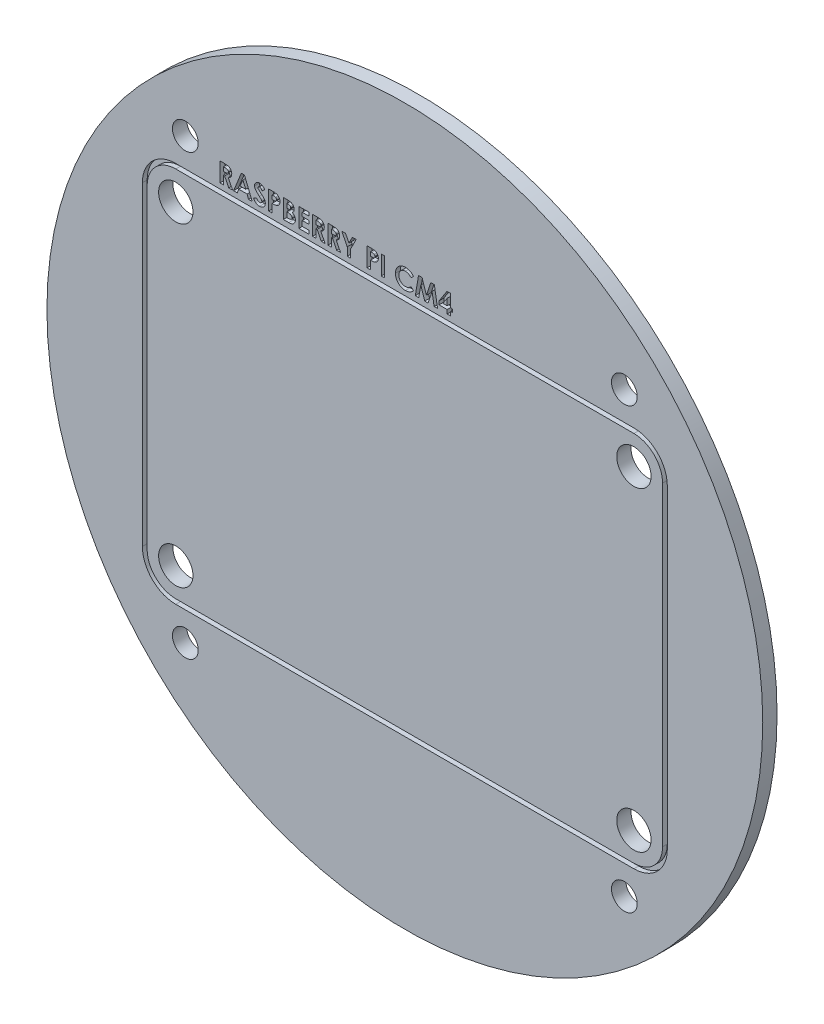
from build123d import *

# Parameters (mm, degrees)
ESQUISSE1_R             = 37.5
BOSS_EXTRU_1_DEPTH      = 1.5
D_GAGEMENT_M2_51_D      = 2.7
D_GAGEMENT_M31_D        = 3.6
ENL_V_MAT_EXTRU_1_DEPTH = 0.5
ESQUISSE7_W             = 0.358974359
ESQUISSE7_H             = 2
ENL_V_MAT_EXTRU_2_DEPTH = 0.5


with BuildPart() as part:
    # Esquisse1 → Boss.-Extru.1 (new body)
    with BuildSketch(Plane.XY):
        Circle(ESQUISSE1_R)
    extrude(amount=BOSS_EXTRU_1_DEPTH)

    # Dégagement M2.51 (through all)
    with Locations(Plane.XY.offset(1.5)):
        with Locations((-23, 23), (23, 23), (23, -23), (-23, -23)):
            Hole(D_GAGEMENT_M2_51_D / 2)

    # Dégagement M31 (through all)
    with Locations(Plane.XY.offset(1.5)):
        with Locations((-24, 16.5), (24, 16.5), (24, -16.5), (-24, -16.5)):
            Hole(D_GAGEMENT_M31_D / 2)

    # Esquisse6 → Enlèv. mat.-Extru.1 (cut)
    with BuildSketch(Plane.XY.offset(1.5)):
        with BuildLine():
            Line((-27.5, 16.5), (-27.5, -16.5))
            ThreePointArc((-27.5, -16.5), (-26.474873734, -18.974873734), (-24, -20))
            Line((-24, -20), (24, -20))
            ThreePointArc((24, -20), (26.474873734, -18.974873734), (27.5, -16.5))
            Line((27.5, -16.5), (27.5, 16.5))
            ThreePointArc((27.5, 16.5), (26.474873734, 18.974873734), (24, 20))
            Line((24, 20), (-24, 20))
            ThreePointArc((-24, 20), (-26.474873734, 18.974873734), (-27.5, 16.5))
        make_face()
        with BuildLine():
            Line((-24, 19.5), (24, 19.5))
            ThreePointArc((24, 19.5), (26.121320344, 18.621320344), (27, 16.5))
            Line((27, 16.5), (27, -16.5))
            ThreePointArc((27, -16.5), (26.121320344, -18.621320344), (24, -19.5))
            Line((24, -19.5), (-24, -19.5))
            ThreePointArc((-24, -19.5), (-26.121320344, -18.621320344), (-27, -16.5))
            Line((-27, -16.5), (-27, 16.5))
            ThreePointArc((-27, 16.5), (-26.121320344, 18.621320344), (-24, 19.5))
        make_face(mode=Mode.SUBTRACT)
    extrude(amount=-ENL_V_MAT_EXTRU_1_DEPTH, mode=Mode.SUBTRACT)

    # Esquisse7 → Enlèv. mat.-Extru.2 (cut)
    with BuildSketch(Plane.XY.offset(1.5)):
        with BuildLine():
            Line((-19.36550309, 22.554763031), (-18.947233859, 22.554763031))
            add(Edge.make_bspline(
                [(-18.947233859, 22.554763031), (-18.91958639, 22.554664898), (-18.86641252, 22.554476162), (-18.789738703, 22.551498396), (-18.719303258, 22.547354591), (-18.655001898, 22.541031034), (-18.596862133, 22.532646763), (-18.544825694, 22.522763094), (-18.498894101, 22.511498534), (-18.458679984, 22.497462003), (-18.422388732, 22.48162901), (-18.38856024, 22.46343661), (-18.356448201, 22.443087382), (-18.326267249, 22.420045883), (-18.297755104, 22.394726623), (-18.270857977, 22.367104116), (-18.245955949, 22.336944135), (-18.223203215, 22.304437252), (-18.202465929, 22.270240757), (-18.184138518, 22.234307697), (-18.169234636, 22.196613084), (-18.156065459, 22.157701686), (-18.146580128, 22.117017256), (-18.139983218, 22.074955866), (-18.135153219, 22.031369454), (-18.134875518, 22.001758781), (-18.134733859, 21.986654057)],
                knots=[0, 0, 0, 0, 8.2937e-05, 0.00015951, 0.000230161, 0.000294583, 0.000353282, 0.00040632, 0.000453447, 0.000495006, 0.000533936, 0.000572115, 0.000610125, 0.000647867, 0.000685896, 0.000724428, 0.000763414, 0.000803096, 0.00084336, 0.000883316, 0.000923937, 0.000964859, 0.00100645, 0.001049066, 0.001092559, 0.001137847, 0.001137847, 0.001137847, 0.001137847], degree=3))
            add(Edge.make_bspline(
                [(-18.134733859, 21.986654057), (-18.135101837, 21.970888195), (-18.135823376, 21.939974213), (-18.139709975, 21.894564094), (-18.146813457, 21.85111887), (-18.157572715, 21.80976574), (-18.169939084, 21.769990019), (-18.186383182, 21.732525592), (-18.204941973, 21.696827595), (-18.226983706, 21.663400987), (-18.251173432, 21.631503299), (-18.279305573, 21.602356649), (-18.309557601, 21.574394513), (-18.343630091, 21.549368347), (-18.380021096, 21.525585971), (-18.419453668, 21.504032804), (-18.461670455, 21.484167051), (-18.491350948, 21.473088534), (-18.506528731, 21.467423287)],
                knots=[0, 0, 0, 0, 4.7303e-05, 9.2752e-05, 0.000136618, 0.000179179, 0.000220863, 0.000261423, 0.000301746, 0.000341418, 0.000381406, 0.00042165, 0.000462775, 0.000504843, 0.000548293, 0.000593122, 0.000639545, 0.000688128, 0.000688128, 0.000688128, 0.000688128], degree=3))
            Line((-18.506528731, 21.467423287), (-18.044990269, 20.554763031))
            Line((-18.044990269, 20.554763031), (-18.444028731, 20.554763031))
            Line((-18.444028731, 20.554763031), (-18.884733859, 21.426557903))
            Line((-18.884733859, 21.426557903), (-19.006528731, 21.426557903))
            Line((-19.006528731, 21.426557903), (-19.006528731, 20.554763031))
            Line((-19.006528731, 20.554763031), (-19.36550309, 20.554763031))
            Line((-19.36550309, 20.554763031), (-19.36550309, 22.554763031))
        make_face()
        with BuildLine():
            Line((-19.006528731, 21.785532262), (-18.866705013, 21.785532262))
            add(Edge.make_bspline(
                [(-18.866705013, 21.785532262), (-18.849610401, 21.785724793), (-18.816877893, 21.786093448), (-18.769804246, 21.787803425), (-18.727050149, 21.791923625), (-18.688432, 21.797129344), (-18.653755477, 21.803140097), (-18.623329881, 21.811753872), (-18.596686402, 21.82098375), (-18.574140764, 21.832454094), (-18.554878289, 21.845498363), (-18.538246375, 21.860316977), (-18.524489397, 21.877467636), (-18.513166703, 21.896484258), (-18.504358878, 21.917535042), (-18.49792984, 21.940388897), (-18.494336959, 21.965306158), (-18.493923586, 21.982502461), (-18.493708218, 21.991461749)],
                knots=[0, 0, 0, 0, 5.1288e-05, 9.8206e-05, 0.000141261, 0.000180074, 0.00021512, 0.00024671, 0.000274846, 0.000299573, 0.000322353, 0.000344479, 0.000366129, 0.000388047, 0.000410668, 0.000434387, 0.000459091, 0.000485961, 0.000485961, 0.000485961, 0.000485961], degree=3))
            add(Edge.make_bspline(
                [(-18.493708218, 21.991461749), (-18.49411539, 22.002061241), (-18.494915205, 22.022881979), (-18.502851855, 22.052856541), (-18.515485288, 22.080600049), (-18.532802263, 22.105987151), (-18.554610743, 22.128243237), (-18.579637694, 22.147862154), (-18.608423258, 22.163375326), (-18.635076524, 22.173607649), (-18.659324766, 22.179729753), (-18.68120804, 22.184291891), (-18.706549002, 22.187525209), (-18.735366785, 22.190954719), (-18.76758793, 22.193178582), (-18.803388062, 22.194801559), (-18.842664364, 22.195465598), (-18.870043676, 22.19567788), (-18.884333218, 22.195788672)],
                knots=[0, 0, 0, 0, 3.1742e-05, 6.2351e-05, 9.2292e-05, 0.000122851, 0.000154019, 0.000185433, 0.000217887, 0.000251743, 0.000270789, 0.000292868, 0.000318762, 0.000347387, 0.000379928, 0.000415621, 0.000454892, 0.000497762, 0.000497762, 0.000497762, 0.000497762], degree=3))
            Line((-18.884333218, 22.195788672), (-19.006528731, 22.195788672))
            Line((-19.006528731, 22.195788672), (-19.006528731, 21.785532262))
        make_face(mode=Mode.SUBTRACT)
        Polygon((-17.134333218, 22.554763031), (-16.801400526, 22.554763031), (-15.993708218, 20.554763031), (-16.377121679, 20.554763031), (-16.532570397, 20.965019441), (-17.403964628, 20.965019441), (-17.559413346, 20.554763031), (-17.942426167, 20.554763031), align=None)
        Polygon((-16.968067192, 22.018304698), (-17.267746679, 21.3239938), (-16.668387705, 21.3239938), align=None, mode=Mode.SUBTRACT)
        with BuildLine():
            Line((-14.673195397, 22.287535467), (-14.941624885, 22.041942518))
            add(Edge.make_bspline(
                [(-14.941624885, 22.041942518), (-14.953123253, 22.058162162), (-14.975198516, 22.089301616), (-15.010980216, 22.130998079), (-15.046600343, 22.166568265), (-15.082388896, 22.195863578), (-15.118663091, 22.218706028), (-15.155359962, 22.234878734), (-15.192271463, 22.245159877), (-15.217070294, 22.246440127), (-15.229285141, 22.247070723)],
                knots=[0, 0, 0, 0, 5.9619e-05, 0.00011446, 0.000164604, 0.000210468, 0.000252936, 0.000292761, 0.000330466, 0.000367065, 0.000367065, 0.000367065, 0.000367065], degree=3))
            add(Edge.make_bspline(
                [(-15.229285141, 22.247070723), (-15.2406788, 22.246671149), (-15.262676961, 22.245899675), (-15.294036972, 22.238231281), (-15.321878836, 22.22499676), (-15.346175382, 22.20769151), (-15.36542183, 22.186842695), (-15.380788627, 22.16497765), (-15.389441425, 22.140843584), (-15.390580303, 22.124267335), (-15.391144115, 22.116061108)],
                knots=[0, 0, 0, 0, 3.4139e-05, 6.5914e-05, 9.6023e-05, 0.000126157, 0.000154782, 0.000180784, 0.000205874, 0.000230474, 0.000230474, 0.000230474, 0.000230474], degree=3))
            add(Edge.make_bspline(
                [(-15.391144115, 22.116061108), (-15.390790803, 22.107736544), (-15.39007928, 22.090972028), (-15.383206941, 22.066401542), (-15.372848363, 22.042393318), (-15.362950319, 22.027778369), (-15.35789091, 22.020307903)],
                knots=[0, 0, 0, 0, 2.492e-05, 5.0186e-05, 7.6017e-05, 0.000103027, 0.000103027, 0.000103027, 0.000103027], degree=3))
            add(Edge.make_bspline(
                [(-15.35789091, 22.020307903), (-15.35329136, 22.014501188), (-15.342703803, 22.001134896), (-15.322515501, 21.979964774), (-15.297163233, 21.954029521), (-15.265671391, 21.924220974), (-15.229347288, 21.889467103), (-15.186507254, 21.851134095), (-15.138384414, 21.80803482), (-15.104179813, 21.778022046), (-15.086256295, 21.762295082)],
                knots=[0, 0, 0, 0, 2.2213e-05, 5.1131e-05, 8.7678e-05, 0.00013103, 0.000181194, 0.00023849, 0.000303469, 0.000375003, 0.000375003, 0.000375003, 0.000375003], degree=3))
            add(Edge.make_bspline(
                [(-15.086256295, 21.762295082), (-15.069432495, 21.747734932), (-15.037504417, 21.720102791), (-14.992077103, 21.680883404), (-14.952154059, 21.645598678), (-14.917153699, 21.61477816), (-14.887606594, 21.588098474), (-14.863388527, 21.565432091), (-14.844203715, 21.547220283), (-14.833298273, 21.53622034), (-14.828644115, 21.531525852)],
                knots=[0, 0, 0, 0, 6.6749e-05, 0.000126675, 0.000180043, 0.00022659, 0.000266584, 0.000299465, 0.000326101, 0.000345932, 0.000345932, 0.000345932, 0.000345932], degree=3))
            add(Edge.make_bspline(
                [(-14.828644115, 21.531525852), (-14.81098721, 21.512417298), (-14.777044437, 21.475683948), (-14.732930798, 21.418758809), (-14.696623845, 21.363188265), (-14.668536099, 21.307926667), (-14.647323103, 21.252176701), (-14.63236766, 21.194571101), (-14.623410745, 21.134507925), (-14.622416319, 21.093522139), (-14.621913346, 21.072791877)],
                knots=[0, 0, 0, 0, 7.8022e-05, 0.000149986, 0.000215775, 0.000276874, 0.000335583, 0.000394373, 0.000455112, 0.000517275, 0.000517275, 0.000517275, 0.000517275], degree=3))
            add(Edge.make_bspline(
                [(-14.621913346, 21.072791877), (-14.622271349, 21.052592779), (-14.622973764, 21.012961397), (-14.631577003, 20.954966773), (-14.643844716, 20.899463401), (-14.662812753, 20.847055235), (-14.685930884, 20.796882013), (-14.714912801, 20.749725273), (-14.748948088, 20.705107769), (-14.787957752, 20.663827095), (-14.831107073, 20.626367744), (-14.877388821, 20.593020545), (-14.927255561, 20.565488185), (-14.980281241, 20.54281725), (-15.036437477, 20.525355793), (-15.095657369, 20.512450149), (-15.1580315, 20.504704385), (-15.200683829, 20.503894657), (-15.222474244, 20.50348098)],
                knots=[0, 0, 0, 0, 6.0545e-05, 0.000118791, 0.000175546, 0.000230794, 0.000285639, 0.000341021, 0.000396471, 0.000453722, 0.000511085, 0.000567672, 0.000624525, 0.000681604, 0.000740398, 0.000800672, 0.000863236, 0.000928585, 0.000928585, 0.000928585, 0.000928585], degree=3))
            add(Edge.make_bspline(
                [(-15.222474244, 20.50348098), (-15.239579534, 20.503784439), (-15.273457818, 20.504385462), (-15.323389287, 20.509292318), (-15.371603766, 20.51721146), (-15.418046943, 20.528561957), (-15.462928055, 20.542944575), (-15.506248944, 20.560512393), (-15.547710552, 20.581537704), (-15.587626597, 20.605588145), (-15.625803038, 20.633513875), (-15.662722601, 20.664743962), (-15.698018566, 20.699758738), (-15.731860451, 20.738475394), (-15.764031728, 20.781003568), (-15.795585478, 20.826750975), (-15.825119357, 20.876566626), (-15.843363747, 20.911512707), (-15.852682577, 20.92936239)],
                knots=[0, 0, 0, 0, 5.1307e-05, 0.000101617, 0.000150358, 0.000197777, 0.00024491, 0.000291632, 0.000337859, 0.000384238, 0.000431279, 0.000479603, 0.00052918, 0.000580287, 0.000633734, 0.000689075, 0.000746929, 0.000807331, 0.000807331, 0.000807331, 0.000807331], degree=3))
            Line((-15.852682577, 20.92936239), (-15.536977449, 21.118865595))
            add(Edge.make_bspline(
                [(-15.536977449, 21.118865595), (-15.525320985, 21.098603873), (-15.502974549, 21.05976042), (-15.465106424, 21.007569318), (-15.426312463, 20.962876278), (-15.385695784, 20.926471253), (-15.343750272, 20.89786746), (-15.300273319, 20.877425206), (-15.25523438, 20.864771473), (-15.2245559, 20.86322616), (-15.20925309, 20.862455339)],
                knots=[0, 0, 0, 0, 7.0084e-05, 0.000134356, 0.000193114, 0.000247313, 0.000297539, 0.000344857, 0.000390924, 0.000436772, 0.000436772, 0.000436772, 0.000436772], degree=3))
            add(Edge.make_bspline(
                [(-15.20925309, 20.862455339), (-15.193687941, 20.863084833), (-15.163489284, 20.864306145), (-15.120384567, 20.875587029), (-15.08086453, 20.893298844), (-15.046703702, 20.918571163), (-15.017778466, 20.947739259), (-14.996429982, 20.9801901), (-14.983018721, 21.015301127), (-14.981600825, 21.039691556), (-14.980887705, 21.051958544)],
                knots=[0, 0, 0, 0, 4.6614e-05, 9.0438e-05, 0.000132747, 0.000175782, 0.000217147, 0.000255374, 0.000291623, 0.0003283, 0.0003283, 0.0003283, 0.0003283], degree=3))
            add(Edge.make_bspline(
                [(-14.980887705, 21.051958544), (-14.981546242, 21.06337098), (-14.982883998, 21.086554252), (-14.992737493, 21.121024048), (-15.00814151, 21.155478169), (-15.02636555, 21.183738371), (-15.044910792, 21.207399872), (-15.062644226, 21.227901492), (-15.084238858, 21.250552194), (-15.109639932, 21.275380469), (-15.138511836, 21.302604887), (-15.170878889, 21.332222783), (-15.207111728, 21.363973258), (-15.232721171, 21.385601368), (-15.246112064, 21.396910467)],
                knots=[0, 0, 0, 0, 3.4205e-05, 6.9484e-05, 0.000106787, 0.000147132, 0.000169972, 0.000196959, 0.000228416, 0.000263829, 0.000303507, 0.000347462, 0.000395441, 0.000448022, 0.000448022, 0.000448022, 0.000448022], degree=3))
            add(Edge.make_bspline(
                [(-15.246112064, 21.396910467), (-15.271568685, 21.418449209), (-15.320427645, 21.459788575), (-15.389471555, 21.520845517), (-15.4516863, 21.577908824), (-15.506534527, 21.631683922), (-15.554715086, 21.681177712), (-15.595901679, 21.7267922), (-15.629641852, 21.768879239), (-15.665146108, 21.81872852), (-15.69888225, 21.879473295), (-15.728039851, 21.952556301), (-15.746956071, 22.025630034), (-15.749075371, 22.074687713), (-15.750118474, 22.098833544)],
                knots=[0, 0, 0, 0, 0.000100035, 0.000191998, 0.000276488, 0.000353266, 0.0004224, 0.000483686, 0.000537559, 0.000584133, 0.000667175, 0.000745218, 0.000819846, 0.000892179, 0.000892179, 0.000892179, 0.000892179], degree=3))
            add(Edge.make_bspline(
                [(-15.750118474, 22.098833544), (-15.749684649, 22.115956471), (-15.748829966, 22.149690477), (-15.741206065, 22.199291417), (-15.729811854, 22.247152156), (-15.713264188, 22.293098078), (-15.691787317, 22.337071631), (-15.66570449, 22.379288087), (-15.634610692, 22.419358893), (-15.59957008, 22.457257486), (-15.560964298, 22.491892488), (-15.519709113, 22.522461347), (-15.476038034, 22.54828025), (-15.430218219, 22.569698904), (-15.38196574, 22.586093524), (-15.331636073, 22.597714847), (-15.279157027, 22.60462684), (-15.243461913, 22.605566445), (-15.225278731, 22.606045082)],
                knots=[0, 0, 0, 0, 5.1338e-05, 0.000101142, 0.000150214, 0.000198751, 0.000247309, 0.000296785, 0.00034735, 0.000399231, 0.000451434, 0.000502718, 0.000553014, 0.000603382, 0.000654187, 0.000705598, 0.000758124, 0.000812665, 0.000812665, 0.000812665, 0.000812665], degree=3))
            add(Edge.make_bspline(
                [(-15.225278731, 22.606045082), (-15.201714226, 22.605183043), (-15.154771228, 22.603465768), (-15.08536465, 22.590037239), (-15.017571207, 22.568919463), (-14.96294198, 22.54344319), (-14.919474524, 22.518764312), (-14.886160779, 22.49604311), (-14.85226225, 22.470014752), (-14.817505568, 22.440597216), (-14.782536564, 22.407236237), (-14.746360902, 22.370725998), (-14.709471521, 22.330750967), (-14.685499272, 22.30219299), (-14.673195397, 22.287535467)],
                knots=[0, 0, 0, 0, 7.065e-05, 0.000140743, 0.000211321, 0.000283207, 0.000321073, 0.000361187, 0.000404058, 0.000449252, 0.000497716, 0.000548994, 0.000603434, 0.000660839, 0.000660839, 0.000660839, 0.000660839], degree=3))
        make_face()
        with BuildLine():
            Line((-14.262938987, 22.554763031), (-13.862297961, 22.554763031))
            add(Edge.make_bspline(
                [(-13.862297961, 22.554763031), (-13.836120597, 22.554645856), (-13.785618973, 22.5544198), (-13.712791476, 22.55167857), (-13.645604544, 22.546766119), (-13.584073614, 22.540695106), (-13.528223985, 22.532183783), (-13.477985717, 22.522426217), (-13.433348384, 22.510538662), (-13.393808633, 22.496428299), (-13.358322985, 22.479792732), (-13.324742116, 22.462074666), (-13.293824958, 22.440928779), (-13.264011029, 22.418634085), (-13.237004843, 22.393060781), (-13.211121592, 22.365910806), (-13.187457502, 22.336107416), (-13.165902923, 22.304011372), (-13.146349598, 22.270215672), (-13.129266505, 22.2346599), (-13.115409657, 22.197287791), (-13.103785485, 22.158341102), (-13.094448836, 22.117821529), (-13.088234066, 22.075479873), (-13.084012681, 22.03161178), (-13.083640202, 22.001755129), (-13.083451808, 21.986654057)],
                knots=[0, 0, 0, 0, 7.853e-05, 0.0001515, 0.00021858, 0.000280611, 0.000336932, 0.000388004, 0.00043407, 0.000475385, 0.000513748, 0.000551574, 0.000589132, 0.000625993, 0.000663132, 0.000700545, 0.000738462, 0.000777131, 0.000816439, 0.000855505, 0.000895316, 0.000935878, 0.000977379, 0.001019932, 0.001064184, 0.001109472, 0.001109472, 0.001109472, 0.001109472], degree=3))
            add(Edge.make_bspline(
                [(-13.083451808, 21.986654057), (-13.083724391, 21.9699481), (-13.084260051, 21.937118842), (-13.089511243, 21.888995178), (-13.098481938, 21.843113621), (-13.110206168, 21.799087244), (-13.126554772, 21.757640379), (-13.145232285, 21.71778409), (-13.16821155, 21.680635826), (-13.194469034, 21.645730906), (-13.223145202, 21.612785538), (-13.254920825, 21.582750956), (-13.289190246, 21.555422415), (-13.325755092, 21.530513511), (-13.364752638, 21.50807449), (-13.406154745, 21.487895235), (-13.450244131, 21.470621141), (-13.480946652, 21.461586929), (-13.496512705, 21.457006621)],
                knots=[0, 0, 0, 0, 5.0106e-05, 9.8464e-05, 0.00014498, 0.000190273, 0.000234916, 0.00027846, 0.000322162, 0.000365671, 0.000409391, 0.000453033, 0.000496644, 0.00054076, 0.000585634, 0.000631505, 0.000678823, 0.000727484, 0.000727484, 0.000727484, 0.000727484], degree=3))
            add(Edge.make_bspline(
                [(-13.496512705, 21.457006621), (-13.506765403, 21.454455733), (-13.528976047, 21.448929689), (-13.565728564, 21.443319367), (-13.60808198, 21.438161021), (-13.656173253, 21.433728047), (-13.710030108, 21.430714657), (-13.769600397, 21.428361334), (-13.834911117, 21.426650225), (-13.880325609, 21.426589507), (-13.903964628, 21.426557903)],
                knots=[0, 0, 0, 0, 3.1681e-05, 6.8631e-05, 0.000111418, 0.000159696, 0.000213477, 0.000273221, 0.000338546, 0.00040946, 0.00040946, 0.00040946, 0.00040946], degree=3))
            Line((-13.903964628, 21.426557903), (-13.903964628, 20.554763031))
            Line((-13.903964628, 20.554763031), (-14.262938987, 20.554763031))
            Line((-14.262938987, 20.554763031), (-14.262938987, 22.554763031))
        make_face()
        with BuildLine():
            Line((-13.903964628, 21.785532262), (-13.776961423, 21.785532262))
            add(Edge.make_bspline(
                [(-13.776961423, 21.785532262), (-13.753851185, 21.785678799), (-13.711328003, 21.785948429), (-13.653256353, 21.789847435), (-13.606588858, 21.795802005), (-13.569720671, 21.804342235), (-13.540609744, 21.817303166), (-13.515503393, 21.832296522), (-13.493969035, 21.851255209), (-13.47532345, 21.872918753), (-13.460416867, 21.897811251), (-13.450079928, 21.925527377), (-13.443365255, 21.955484785), (-13.442745093, 21.976333158), (-13.442426167, 21.987054698)],
                knots=[0, 0, 0, 0, 6.9321e-05, 0.000127552, 0.000174467, 0.00021042, 0.000240564, 0.000269698, 0.000297814, 0.000326234, 0.000355161, 0.000384328, 0.00041466, 0.000446774, 0.000446774, 0.000446774, 0.000446774], degree=3))
            add(Edge.make_bspline(
                [(-13.442426167, 21.987054698), (-13.442741812, 21.996421967), (-13.443354241, 22.014596722), (-13.447853308, 22.040827402), (-13.455023528, 22.065279806), (-13.4654129, 22.087698562), (-13.478843898, 22.108045578), (-13.495219003, 22.126312836), (-13.514328089, 22.142891548), (-13.529081421, 22.151666913), (-13.536576808, 22.156125211)],
                knots=[0, 0, 0, 0, 2.8091e-05, 5.4503e-05, 7.9599e-05, 0.000104336, 0.000128337, 0.000152459, 0.00017775, 0.000203869, 0.000203869, 0.000203869, 0.000203869], degree=3))
            add(Edge.make_bspline(
                [(-13.536576808, 22.156125211), (-13.542925832, 22.159336094), (-13.556368019, 22.166134194), (-13.579261366, 22.174037481), (-13.605679939, 22.180704775), (-13.635802093, 22.186238564), (-13.669507662, 22.190533359), (-13.706790633, 22.193817803), (-13.74770587, 22.195138606), (-13.77615997, 22.195566007), (-13.790983859, 22.195788672)],
                knots=[0, 0, 0, 0, 2.1324e-05, 4.5148e-05, 7.2454e-05, 0.000103021, 0.000136962, 0.000174359, 0.000215256, 0.000259734, 0.000259734, 0.000259734, 0.000259734], degree=3))
            Line((-13.790983859, 22.195788672), (-13.903964628, 22.195788672))
            Line((-13.903964628, 22.195788672), (-13.903964628, 21.785532262))
        make_face(mode=Mode.SUBTRACT)
        with BuildLine():
            Line((-12.724477449, 20.554763031), (-12.724477449, 22.554763031))
            Line((-12.724477449, 22.554763031), (-12.403964628, 22.554763031))
            add(Edge.make_bspline(
                [(-12.403964628, 22.554763031), (-12.381526727, 22.554765592), (-12.338109813, 22.554770547), (-12.275470536, 22.552570861), (-12.217377898, 22.549725321), (-12.16401677, 22.546541824), (-12.115296329, 22.541056021), (-12.071290662, 22.535274585), (-12.031911845, 22.528302529), (-12.007566062, 22.522048379), (-11.996112064, 22.51910598)],
                knots=[0, 0, 0, 0, 6.7309e-05, 0.000130241, 0.000188002, 0.000241809, 0.000290565, 0.000335044, 0.000374963, 0.000410431, 0.000410431, 0.000410431, 0.000410431], degree=3))
            add(Edge.make_bspline(
                [(-11.996112064, 22.51910598), (-11.981071802, 22.514955673), (-11.95155798, 22.506811438), (-11.909284768, 22.490363804), (-11.869182729, 22.472081093), (-11.831300828, 22.451223939), (-11.795871674, 22.427540537), (-11.76302991, 22.40084293), (-11.73206722, 22.372202758), (-11.704083019, 22.340821828), (-11.678789912, 22.307662062), (-11.656814736, 22.272732149), (-11.637721126, 22.23656619), (-11.622441236, 22.198709062), (-11.610928126, 22.159335105), (-11.602507485, 22.118612454), (-11.59704977, 22.076412251), (-11.596534088, 22.047702074), (-11.59627232, 22.033128416)],
                knots=[0, 0, 0, 0, 4.6779e-05, 9.1795e-05, 0.000135895, 0.000178934, 0.000221381, 0.000263553, 0.000305788, 0.000347777, 0.000389524, 0.000430761, 0.00047144, 0.000512061, 0.000553007, 0.000594337, 0.000636725, 0.000680424, 0.000680424, 0.000680424, 0.000680424], degree=3))
            add(Edge.make_bspline(
                [(-11.59627232, 22.033128416), (-11.596956764, 22.014405091), (-11.598304006, 21.977550526), (-11.606910283, 21.923417837), (-11.623048393, 21.872254666), (-11.644164717, 21.823118094), (-11.672876315, 21.776191402), (-11.709334493, 21.7314969), (-11.752948746, 21.687658379), (-11.786403286, 21.661380143), (-11.803804372, 21.647711749)],
                knots=[0, 0, 0, 0, 5.6181e-05, 0.000110586, 0.000163812, 0.000216736, 0.000270674, 0.000328239, 0.00038943, 0.000455759, 0.000455759, 0.000455759, 0.000455759], degree=3))
            add(Edge.make_bspline(
                [(-11.803804372, 21.647711749), (-11.789703367, 21.640513308), (-11.762055197, 21.626399158), (-11.72280292, 21.603199707), (-11.686459595, 21.578524149), (-11.652862271, 21.552868966), (-11.62271569, 21.525146598), (-11.59477505, 21.496954444), (-11.570418796, 21.466677213), (-11.5486387, 21.435394042), (-11.529707794, 21.402651947), (-11.513221062, 21.368506223), (-11.499295312, 21.33284022), (-11.487502626, 21.29583545), (-11.478707638, 21.257364632), (-11.472973118, 21.217414009), (-11.468582412, 21.176119833), (-11.468240856, 21.147991271), (-11.468067192, 21.133689313)],
                knots=[0, 0, 0, 0, 4.7489e-05, 9.3113e-05, 0.000136672, 0.000179225, 0.000219785, 0.000259451, 0.000298182, 0.000336191, 0.00037371, 0.000411519, 0.000449834, 0.000488481, 0.00052794, 0.000568056, 0.000609516, 0.000652401, 0.000652401, 0.000652401, 0.000652401], degree=3))
            add(Edge.make_bspline(
                [(-11.468067192, 21.133689313), (-11.469194155, 21.106373392), (-11.471418211, 21.052465531), (-11.487679423, 20.97331641), (-11.515871197, 20.898275865), (-11.553726937, 20.827642138), (-11.600372492, 20.76345996), (-11.654001503, 20.70723693), (-11.714074051, 20.659645383), (-11.769498236, 20.627524781), (-11.817435792, 20.605968853), (-11.857141574, 20.592641619), (-11.899784742, 20.58029529), (-11.946146417, 20.571625443), (-11.995386124, 20.563689845), (-12.047983955, 20.558790243), (-12.103841604, 20.555469903), (-12.142207052, 20.555003419), (-12.161977449, 20.554763031)],
                knots=[0, 0, 0, 0, 8.1923e-05, 0.000161675, 0.000241156, 0.000321638, 0.000401375, 0.00047845, 0.000554036, 0.000630516, 0.000669975, 0.000711533, 0.000756055, 0.000803041, 0.000852904, 0.000905646, 0.000961427, 0.001020734, 0.001020734, 0.001020734, 0.001020734], degree=3))
            Line((-12.161977449, 20.554763031), (-12.724477449, 20.554763031))
        make_face()
        with BuildLine():
            Line((-12.36550309, 22.195788672), (-12.36550309, 21.759891236))
            Line((-12.36550309, 21.759891236), (-12.270150526, 21.759891236))
            add(Edge.make_bspline(
                [(-12.270150526, 21.759891236), (-12.257191255, 21.760004246), (-12.232174169, 21.760222404), (-12.19603964, 21.76303221), (-12.162440365, 21.767825912), (-12.131503776, 21.774514332), (-12.10294169, 21.783007651), (-12.076936567, 21.793226943), (-12.05360275, 21.80569559), (-12.02649425, 21.82426819), (-11.997838612, 21.851598601), (-11.972613375, 21.891083044), (-11.957755879, 21.936490003), (-11.956101155, 21.968514506), (-11.955246679, 21.985051493)],
                knots=[0, 0, 0, 0, 3.887e-05, 7.5037e-05, 0.000108636, 0.00014062, 0.000169899, 0.000197947, 0.000224295, 0.000249077, 0.000296395, 0.000341964, 0.000388335, 0.000437847, 0.000437847, 0.000437847, 0.000437847], degree=3))
            add(Edge.make_bspline(
                [(-11.955246679, 21.985051493), (-11.955930416, 22.000541128), (-11.957252394, 22.030489717), (-11.972211982, 22.072540202), (-11.99544718, 22.109805538), (-12.022879597, 22.135310613), (-12.048712547, 22.152729827), (-12.070832305, 22.164199638), (-12.0951104, 22.174467296), (-12.122016831, 22.182318197), (-12.151397946, 22.188209236), (-12.183111026, 22.1925355), (-12.217210786, 22.195480138), (-12.240763563, 22.195683622), (-12.252922961, 22.195788672)],
                knots=[0, 0, 0, 0, 4.6284e-05, 8.9488e-05, 0.000132169, 0.000176944, 0.000200613, 0.000225523, 0.000251565, 0.000279578, 0.000309436, 0.000341392, 0.000375562, 0.000412029, 0.000412029, 0.000412029, 0.000412029], degree=3))
            Line((-12.252922961, 22.195788672), (-12.36550309, 22.195788672))
        make_face(mode=Mode.SUBTRACT)
        with BuildLine():
            Line((-12.36550309, 21.426557903), (-12.36550309, 20.91373739))
            Line((-12.36550309, 20.91373739), (-12.262137705, 20.91373739))
            add(Edge.make_bspline(
                [(-12.262137705, 20.91373739), (-12.241702237, 20.913854137), (-12.202412499, 20.914078598), (-12.14613002, 20.916790618), (-12.094955176, 20.921678557), (-12.04902356, 20.927780755), (-12.008264821, 20.936048279), (-11.972816732, 20.946559376), (-11.942193169, 20.958123413), (-11.916577752, 20.972406372), (-11.895651423, 20.989028195), (-11.876767606, 21.006016097), (-11.861370918, 21.025613247), (-11.849188772, 21.046978393), (-11.838645145, 21.06958081), (-11.832285974, 21.094303115), (-11.827444325, 21.120412597), (-11.827177876, 21.138471961), (-11.827041551, 21.147711749)],
                knots=[0, 0, 0, 0, 6.1303e-05, 0.000117863, 0.000168971, 0.000215489, 0.000256819, 0.000293582, 0.000326317, 0.000354842, 0.000381126, 0.000406353, 0.000430881, 0.00045548, 0.00048005, 0.000505421, 0.000531833, 0.000559503, 0.000559503, 0.000559503, 0.000559503], degree=3))
            add(Edge.make_bspline(
                [(-11.827041551, 21.147711749), (-11.827342186, 21.158277592), (-11.827927741, 21.178857013), (-11.832709975, 21.208936032), (-11.841400857, 21.237016792), (-11.852347447, 21.263817355), (-11.867580208, 21.28837817), (-11.885683824, 21.311549191), (-11.907557614, 21.332545777), (-11.932155967, 21.352637879), (-11.96084751, 21.370229604), (-11.993645705, 21.385493541), (-12.030728729, 21.398241419), (-12.072211451, 21.408391288), (-12.117912014, 21.417005341), (-12.168163982, 21.422148882), (-12.222548839, 21.425974359), (-12.260260183, 21.426358968), (-12.27976591, 21.426557903)],
                knots=[0, 0, 0, 0, 3.1691e-05, 6.1726e-05, 9.1006e-05, 0.000119729, 0.000148313, 0.000177408, 0.000207722, 0.000239069, 0.000272534, 0.00030838, 0.000347405, 0.000389965, 0.000436407, 0.0004868, 0.000541407, 0.000599912, 0.000599912, 0.000599912, 0.000599912], degree=3))
            Line((-12.27976591, 21.426557903), (-12.36550309, 21.426557903))
        make_face(mode=Mode.SUBTRACT)
        Polygon((-11.109092833, 22.554763031), (-10.032169756, 22.554763031), (-10.032169756, 22.195788672), (-10.750118474, 22.195788672), (-10.750118474, 21.811173287), (-10.032169756, 21.811173287), (-10.032169756, 21.452198928), (-10.750118474, 21.452198928), (-10.750118474, 20.91373739), (-10.032169756, 20.91373739), (-10.032169756, 20.554763031), (-11.109092833, 20.554763031), align=None)
        with BuildLine():
            Line((-9.673195397, 22.554763031), (-9.254926167, 22.554763031))
            add(Edge.make_bspline(
                [(-9.254926167, 22.554763031), (-9.227278698, 22.554664898), (-9.174104827, 22.554476162), (-9.09743101, 22.551498396), (-9.026995565, 22.547354591), (-8.962694206, 22.541031034), (-8.904554441, 22.532646763), (-8.852518002, 22.522763094), (-8.806586408, 22.511498534), (-8.766372292, 22.497462003), (-8.73008104, 22.48162901), (-8.696252548, 22.46343661), (-8.664140509, 22.443087382), (-8.633959556, 22.420045883), (-8.605447412, 22.394726623), (-8.578550285, 22.367104116), (-8.553648257, 22.336944135), (-8.530895523, 22.304437252), (-8.510158237, 22.270240757), (-8.491830825, 22.234307697), (-8.476926944, 22.196613084), (-8.463757767, 22.157701686), (-8.454272435, 22.117017256), (-8.447675526, 22.074955866), (-8.442845527, 22.031369454), (-8.442567825, 22.001758781), (-8.442426167, 21.986654057)],
                knots=[0, 0, 0, 0, 8.2937e-05, 0.00015951, 0.000230161, 0.000294583, 0.000353282, 0.00040632, 0.000453447, 0.000495006, 0.000533936, 0.000572115, 0.000610125, 0.000647867, 0.000685896, 0.000724428, 0.000763414, 0.000803096, 0.00084336, 0.000883316, 0.000923937, 0.000964859, 0.00100645, 0.001049066, 0.001092559, 0.001137847, 0.001137847, 0.001137847, 0.001137847], degree=3))
            add(Edge.make_bspline(
                [(-8.442426167, 21.986654057), (-8.442794145, 21.970888195), (-8.443515684, 21.939974213), (-8.447402283, 21.894564094), (-8.454505765, 21.85111887), (-8.465265023, 21.80976574), (-8.477631392, 21.769990019), (-8.49407549, 21.732525592), (-8.512634281, 21.696827595), (-8.534676014, 21.663400987), (-8.558865739, 21.631503299), (-8.586997881, 21.602356649), (-8.617249909, 21.574394513), (-8.651322399, 21.549368347), (-8.687713404, 21.525585971), (-8.727145976, 21.504032804), (-8.769362763, 21.484167051), (-8.799043255, 21.473088534), (-8.814221038, 21.467423287)],
                knots=[0, 0, 0, 0, 4.7303e-05, 9.2752e-05, 0.000136618, 0.000179179, 0.000220863, 0.000261423, 0.000301746, 0.000341418, 0.000381406, 0.00042165, 0.000462775, 0.000504843, 0.000548293, 0.000593122, 0.000639545, 0.000688128, 0.000688128, 0.000688128, 0.000688128], degree=3))
            Line((-8.814221038, 21.467423287), (-8.352682577, 20.554763031))
            Line((-8.352682577, 20.554763031), (-8.751721038, 20.554763031))
            Line((-8.751721038, 20.554763031), (-9.192426167, 21.426557903))
            Line((-9.192426167, 21.426557903), (-9.314221038, 21.426557903))
            Line((-9.314221038, 21.426557903), (-9.314221038, 20.554763031))
            Line((-9.314221038, 20.554763031), (-9.673195397, 20.554763031))
            Line((-9.673195397, 20.554763031), (-9.673195397, 22.554763031))
        make_face()
        with BuildLine():
            Line((-9.314221038, 21.785532262), (-9.17439732, 21.785532262))
            add(Edge.make_bspline(
                [(-9.17439732, 21.785532262), (-9.157302709, 21.785724793), (-9.1245702, 21.786093448), (-9.077496554, 21.787803425), (-9.034742457, 21.791923625), (-8.996124308, 21.797129344), (-8.961447785, 21.803140097), (-8.931022189, 21.811753872), (-8.904378709, 21.82098375), (-8.881833072, 21.832454094), (-8.862570597, 21.845498363), (-8.845938683, 21.860316977), (-8.832181705, 21.877467636), (-8.820859011, 21.896484258), (-8.812051186, 21.917535042), (-8.805622148, 21.940388897), (-8.802029267, 21.965306158), (-8.801615893, 21.982502461), (-8.801400526, 21.991461749)],
                knots=[0, 0, 0, 0, 5.1288e-05, 9.8206e-05, 0.000141261, 0.000180074, 0.00021512, 0.00024671, 0.000274846, 0.000299573, 0.000322353, 0.000344479, 0.000366129, 0.000388047, 0.000410668, 0.000434387, 0.000459091, 0.000485961, 0.000485961, 0.000485961, 0.000485961], degree=3))
            add(Edge.make_bspline(
                [(-8.801400526, 21.991461749), (-8.801807698, 22.002061241), (-8.802607513, 22.022881979), (-8.810544163, 22.052856541), (-8.823177596, 22.080600049), (-8.840494571, 22.105987151), (-8.862303051, 22.128243237), (-8.887330001, 22.147862154), (-8.916115565, 22.163375326), (-8.942768832, 22.173607649), (-8.967017074, 22.179729753), (-8.988900347, 22.184291891), (-9.01424131, 22.187525209), (-9.043059093, 22.190954719), (-9.075280238, 22.193178582), (-9.11108037, 22.194801559), (-9.150356672, 22.195465598), (-9.177735984, 22.19567788), (-9.192025526, 22.195788672)],
                knots=[0, 0, 0, 0, 3.1742e-05, 6.2351e-05, 9.2292e-05, 0.000122851, 0.000154019, 0.000185433, 0.000217887, 0.000251743, 0.000270789, 0.000292868, 0.000318762, 0.000347387, 0.000379928, 0.000415621, 0.000454892, 0.000497762, 0.000497762, 0.000497762, 0.000497762], degree=3))
            Line((-9.192025526, 22.195788672), (-9.314221038, 22.195788672))
            Line((-9.314221038, 22.195788672), (-9.314221038, 21.785532262))
        make_face(mode=Mode.SUBTRACT)
        with BuildLine():
            Line((-8.057810782, 22.554763031), (-7.639541551, 22.554763031))
            add(Edge.make_bspline(
                [(-7.639541551, 22.554763031), (-7.611894082, 22.554664898), (-7.558720212, 22.554476162), (-7.482046395, 22.551498396), (-7.41161095, 22.547354591), (-7.34730959, 22.541031034), (-7.289169826, 22.532646763), (-7.237133386, 22.522763094), (-7.191201793, 22.511498534), (-7.150987676, 22.497462003), (-7.114696425, 22.48162901), (-7.080867932, 22.46343661), (-7.048755893, 22.443087382), (-7.018574941, 22.420045883), (-6.990062797, 22.394726623), (-6.96316567, 22.367104116), (-6.938263642, 22.336944135), (-6.915510907, 22.304437252), (-6.894773621, 22.270240757), (-6.87644621, 22.234307697), (-6.861542328, 22.196613084), (-6.848373152, 22.157701686), (-6.83888782, 22.117017256), (-6.832290911, 22.074955866), (-6.827460912, 22.031369454), (-6.82718321, 22.001758781), (-6.827041551, 21.986654057)],
                knots=[0, 0, 0, 0, 8.2937e-05, 0.00015951, 0.000230161, 0.000294583, 0.000353282, 0.00040632, 0.000453447, 0.000495006, 0.000533936, 0.000572115, 0.000610125, 0.000647867, 0.000685896, 0.000724428, 0.000763414, 0.000803096, 0.00084336, 0.000883316, 0.000923937, 0.000964859, 0.00100645, 0.001049066, 0.001092559, 0.001137847, 0.001137847, 0.001137847, 0.001137847], degree=3))
            add(Edge.make_bspline(
                [(-6.827041551, 21.986654057), (-6.82740953, 21.970888195), (-6.828131068, 21.939974213), (-6.832017667, 21.894564094), (-6.83912115, 21.85111887), (-6.849880407, 21.80976574), (-6.862246776, 21.769990019), (-6.878690875, 21.732525592), (-6.897249665, 21.696827595), (-6.919291398, 21.663400987), (-6.943481124, 21.631503299), (-6.971613266, 21.602356649), (-7.001865293, 21.574394513), (-7.035937783, 21.549368347), (-7.072328789, 21.525585971), (-7.11176136, 21.504032804), (-7.153978148, 21.484167051), (-7.18365864, 21.473088534), (-7.198836423, 21.467423287)],
                knots=[0, 0, 0, 0, 4.7303e-05, 9.2752e-05, 0.000136618, 0.000179179, 0.000220863, 0.000261423, 0.000301746, 0.000341418, 0.000381406, 0.00042165, 0.000462775, 0.000504843, 0.000548293, 0.000593122, 0.000639545, 0.000688128, 0.000688128, 0.000688128, 0.000688128], degree=3))
            Line((-7.198836423, 21.467423287), (-6.737297961, 20.554763031))
            Line((-6.737297961, 20.554763031), (-7.136336423, 20.554763031))
            Line((-7.136336423, 20.554763031), (-7.577041551, 21.426557903))
            Line((-7.577041551, 21.426557903), (-7.698836423, 21.426557903))
            Line((-7.698836423, 21.426557903), (-7.698836423, 20.554763031))
            Line((-7.698836423, 20.554763031), (-8.057810782, 20.554763031))
            Line((-8.057810782, 20.554763031), (-8.057810782, 22.554763031))
        make_face()
        with BuildLine():
            Line((-7.698836423, 21.785532262), (-7.559012705, 21.785532262))
            add(Edge.make_bspline(
                [(-7.559012705, 21.785532262), (-7.541918093, 21.785724793), (-7.509185585, 21.786093448), (-7.462111939, 21.787803425), (-7.419357841, 21.791923625), (-7.380739693, 21.797129344), (-7.346063169, 21.803140097), (-7.315637574, 21.811753872), (-7.288994094, 21.82098375), (-7.266448456, 21.832454094), (-7.247185981, 21.845498363), (-7.230554067, 21.860316977), (-7.21679709, 21.877467636), (-7.205474395, 21.896484258), (-7.19666657, 21.917535042), (-7.190237533, 21.940388897), (-7.186644651, 21.965306158), (-7.186231278, 21.982502461), (-7.18601591, 21.991461749)],
                knots=[0, 0, 0, 0, 5.1288e-05, 9.8206e-05, 0.000141261, 0.000180074, 0.00021512, 0.00024671, 0.000274846, 0.000299573, 0.000322353, 0.000344479, 0.000366129, 0.000388047, 0.000410668, 0.000434387, 0.000459091, 0.000485961, 0.000485961, 0.000485961, 0.000485961], degree=3))
            add(Edge.make_bspline(
                [(-7.18601591, 21.991461749), (-7.186423083, 22.002061241), (-7.187222898, 22.022881979), (-7.195159548, 22.052856541), (-7.20779298, 22.080600049), (-7.225109956, 22.105987151), (-7.246918435, 22.128243237), (-7.271945386, 22.147862154), (-7.30073095, 22.163375326), (-7.327384216, 22.173607649), (-7.351632458, 22.179729753), (-7.373515732, 22.184291891), (-7.398856695, 22.187525209), (-7.427674477, 22.190954719), (-7.459895623, 22.193178582), (-7.495695755, 22.194801559), (-7.534972056, 22.195465598), (-7.562351369, 22.19567788), (-7.57664091, 22.195788672)],
                knots=[0, 0, 0, 0, 3.1742e-05, 6.2351e-05, 9.2292e-05, 0.000122851, 0.000154019, 0.000185433, 0.000217887, 0.000251743, 0.000270789, 0.000292868, 0.000318762, 0.000347387, 0.000379928, 0.000415621, 0.000454892, 0.000497762, 0.000497762, 0.000497762, 0.000497762], degree=3))
            Line((-7.57664091, 22.195788672), (-7.698836423, 22.195788672))
            Line((-7.698836423, 22.195788672), (-7.698836423, 21.785532262))
        make_face(mode=Mode.SUBTRACT)
        Polygon((-6.609092833, 22.554763031), (-6.209653731, 22.554763031), (-5.852682577, 21.853240595), (-5.495711423, 22.554763031), (-5.09627232, 22.554763031), (-5.673195397, 21.420948928), (-5.673195397, 20.554763031), (-6.032169756, 20.554763031), (-6.032169756, 21.420948928), align=None)
        with BuildLine():
            Line((-3.955246679, 22.554763031), (-3.554605654, 22.554763031))
            add(Edge.make_bspline(
                [(-3.554605654, 22.554763031), (-3.528428289, 22.554645856), (-3.477926665, 22.5544198), (-3.405099168, 22.55167857), (-3.337912237, 22.546766119), (-3.276381306, 22.540695106), (-3.220531677, 22.532183783), (-3.170293409, 22.522426217), (-3.125656076, 22.510538662), (-3.086116326, 22.496428299), (-3.050630677, 22.479792732), (-3.017049808, 22.462074666), (-2.98613265, 22.440928779), (-2.956318722, 22.418634085), (-2.929312535, 22.393060781), (-2.903429284, 22.365910806), (-2.879765194, 22.336107416), (-2.858210615, 22.304011372), (-2.83865729, 22.270215672), (-2.821574198, 22.2346599), (-2.80771735, 22.197287791), (-2.796093177, 22.158341102), (-2.786756529, 22.117821529), (-2.780541758, 22.075479873), (-2.776320373, 22.03161178), (-2.775947895, 22.001755129), (-2.7757595, 21.986654057)],
                knots=[0, 0, 0, 0, 7.853e-05, 0.0001515, 0.00021858, 0.000280611, 0.000336932, 0.000388004, 0.00043407, 0.000475385, 0.000513748, 0.000551574, 0.000589132, 0.000625993, 0.000663132, 0.000700545, 0.000738462, 0.000777131, 0.000816439, 0.000855505, 0.000895316, 0.000935878, 0.000977379, 0.001019932, 0.001064184, 0.001109472, 0.001109472, 0.001109472, 0.001109472], degree=3))
            add(Edge.make_bspline(
                [(-2.7757595, 21.986654057), (-2.776032083, 21.9699481), (-2.776567743, 21.937118842), (-2.781818935, 21.888995178), (-2.790789631, 21.843113621), (-2.80251386, 21.799087244), (-2.818862465, 21.757640379), (-2.837539977, 21.71778409), (-2.860519242, 21.680635826), (-2.886776726, 21.645730906), (-2.915452894, 21.612785538), (-2.947228517, 21.582750956), (-2.981497939, 21.555422415), (-3.018062784, 21.530513511), (-3.05706033, 21.50807449), (-3.098462437, 21.487895235), (-3.142551823, 21.470621141), (-3.173254345, 21.461586929), (-3.188820397, 21.457006621)],
                knots=[0, 0, 0, 0, 5.0106e-05, 9.8464e-05, 0.00014498, 0.000190273, 0.000234916, 0.00027846, 0.000322162, 0.000365671, 0.000409391, 0.000453033, 0.000496644, 0.00054076, 0.000585634, 0.000631505, 0.000678823, 0.000727484, 0.000727484, 0.000727484, 0.000727484], degree=3))
            add(Edge.make_bspline(
                [(-3.188820397, 21.457006621), (-3.199073095, 21.454455733), (-3.22128374, 21.448929689), (-3.258036256, 21.443319367), (-3.300389673, 21.438161021), (-3.348480945, 21.433728047), (-3.4023378, 21.430714657), (-3.461908089, 21.428361334), (-3.527218809, 21.426650225), (-3.572633301, 21.426589507), (-3.59627232, 21.426557903)],
                knots=[0, 0, 0, 0, 3.1681e-05, 6.8631e-05, 0.000111418, 0.000159696, 0.000213477, 0.000273221, 0.000338546, 0.00040946, 0.00040946, 0.00040946, 0.00040946], degree=3))
            Line((-3.59627232, 21.426557903), (-3.59627232, 20.554763031))
            Line((-3.59627232, 20.554763031), (-3.955246679, 20.554763031))
            Line((-3.955246679, 20.554763031), (-3.955246679, 22.554763031))
        make_face()
        with BuildLine():
            Line((-3.59627232, 21.785532262), (-3.469269115, 21.785532262))
            add(Edge.make_bspline(
                [(-3.469269115, 21.785532262), (-3.446158877, 21.785678799), (-3.403635695, 21.785948429), (-3.345564045, 21.789847435), (-3.29889655, 21.795802005), (-3.262028363, 21.804342235), (-3.232917437, 21.817303166), (-3.207811085, 21.832296522), (-3.186276727, 21.851255209), (-3.167631142, 21.872918753), (-3.152724559, 21.897811251), (-3.14238762, 21.925527377), (-3.135672948, 21.955484785), (-3.135052785, 21.976333158), (-3.134733859, 21.987054698)],
                knots=[0, 0, 0, 0, 6.9321e-05, 0.000127552, 0.000174467, 0.00021042, 0.000240564, 0.000269698, 0.000297814, 0.000326234, 0.000355161, 0.000384328, 0.00041466, 0.000446774, 0.000446774, 0.000446774, 0.000446774], degree=3))
            add(Edge.make_bspline(
                [(-3.134733859, 21.987054698), (-3.135049505, 21.996421967), (-3.135661933, 22.014596722), (-3.140161001, 22.040827402), (-3.14733122, 22.065279806), (-3.157720592, 22.087698562), (-3.17115159, 22.108045578), (-3.187526695, 22.126312836), (-3.206635782, 22.142891548), (-3.221389114, 22.151666913), (-3.2288845, 22.156125211)],
                knots=[0, 0, 0, 0, 2.8091e-05, 5.4503e-05, 7.9599e-05, 0.000104336, 0.000128337, 0.000152459, 0.00017775, 0.000203869, 0.000203869, 0.000203869, 0.000203869], degree=3))
            add(Edge.make_bspline(
                [(-3.2288845, 22.156125211), (-3.235233525, 22.159336094), (-3.248675711, 22.166134194), (-3.271569059, 22.174037481), (-3.297987632, 22.180704775), (-3.328109786, 22.186238564), (-3.361815355, 22.190533359), (-3.399098325, 22.193817803), (-3.440013563, 22.195138606), (-3.468467662, 22.195566007), (-3.483291551, 22.195788672)],
                knots=[0, 0, 0, 0, 2.1324e-05, 4.5148e-05, 7.2454e-05, 0.000103021, 0.000136962, 0.000174359, 0.000215256, 0.000259734, 0.000259734, 0.000259734, 0.000259734], degree=3))
            Line((-3.483291551, 22.195788672), (-3.59627232, 22.195788672))
            Line((-3.59627232, 22.195788672), (-3.59627232, 21.785532262))
        make_face(mode=Mode.SUBTRACT)
        with Locations((-2.288580013, 21.554763031)):
            Rectangle(ESQUISSE7_W, ESQUISSE7_H)
        with BuildLine():
            Line((0.916548192, 22.207807903), (0.653327039, 21.956205339))
            add(Edge.make_bspline(
                [(0.653327039, 21.956205339), (0.630998476, 21.97929311), (0.587383798, 22.02439076), (0.517104138, 22.084096075), (0.44401585, 22.133852377), (0.369540722, 22.175756817), (0.292339161, 22.207460513), (0.213303829, 22.23056353), (0.13193006, 22.244648566), (0.076859423, 22.246260143), (0.049160372, 22.247070723)],
                knots=[0, 0, 0, 0, 9.6321e-05, 0.000188144, 0.000276046, 0.000361228, 0.000444037, 0.000525816, 0.000607884, 0.000690934, 0.000690934, 0.000690934, 0.000690934], degree=3))
            add(Edge.make_bspline(
                [(0.049160372, 22.247070723), (0.026028298, 22.246430337), (-0.019620301, 22.245166604), (-0.086644407, 22.235902198), (-0.150756428, 22.220147673), (-0.21217583, 22.198435019), (-0.270721883, 22.170339997), (-0.326517337, 22.135884352), (-0.379424631, 22.095379267), (-0.428744889, 22.049034318), (-0.473861328, 21.998398978), (-0.513724575, 21.944371192), (-0.547116438, 21.887074733), (-0.574520597, 21.827089858), (-0.595867378, 21.764138927), (-0.611111661, 21.698264322), (-0.619928547, 21.629387591), (-0.621244527, 21.582565703), (-0.621913346, 21.558769441)],
                knots=[0, 0, 0, 0, 6.9385e-05, 0.000136924, 0.000202514, 0.00026714, 0.000332009, 0.000396944, 0.000463534, 0.000531562, 0.000599669, 0.00066674, 0.000732637, 0.000798255, 0.000864264, 0.00093171, 0.001000784, 0.00107217, 0.00107217, 0.00107217, 0.00107217], degree=3))
            add(Edge.make_bspline(
                [(-0.621913346, 21.558769441), (-0.6217206, 21.54206756), (-0.621340693, 21.50914781), (-0.617181944, 21.460450362), (-0.610485377, 21.413202325), (-0.600793785, 21.367475266), (-0.588674355, 21.32322956), (-0.574455503, 21.280083499), (-0.556618163, 21.238633266), (-0.536818446, 21.198397443), (-0.513791604, 21.160473915), (-0.488964419, 21.124310683), (-0.462043392, 21.090085017), (-0.432854151, 21.057936831), (-0.400985896, 21.028368531), (-0.367262302, 21.000490961), (-0.3311145, 20.975001992), (-0.29329337, 20.951261951), (-0.253472186, 20.930638775), (-0.212731389, 20.911958162), (-0.170453266, 20.896786726), (-0.127152579, 20.884557166), (-0.08298407, 20.87415775), (-0.037515729, 20.867754511), (0.008858291, 20.862905413), (0.040199344, 20.862606009), (0.055971269, 20.862455339)],
                knots=[0, 0, 0, 0, 5.0095e-05, 9.8737e-05, 0.000146501, 0.000193175, 0.000238855, 0.000284085, 0.000329328, 0.000374121, 0.000418507, 0.000462292, 0.000505654, 0.000549044, 0.000592411, 0.000635963, 0.000680208, 0.000725012, 0.000769814, 0.000814643, 0.00085938, 0.000904397, 0.000949591, 0.000995373, 0.001042056, 0.001089347, 0.001089347, 0.001089347, 0.001089347], degree=3))
            add(Edge.make_bspline(
                [(0.055971269, 20.862455339), (0.082723165, 20.863229146), (0.135283683, 20.864749475), (0.2124238, 20.876638233), (0.285930647, 20.896194568), (0.344662266, 20.919289462), (0.390676938, 20.942095971), (0.425707228, 20.963190868), (0.461931278, 20.986787827), (0.498747437, 21.013777422), (0.536569815, 21.043835767), (0.574730759, 21.077621196), (0.614207196, 21.114021203), (0.640067819, 21.140000604), (0.653327039, 21.153320723)],
                knots=[0, 0, 0, 0, 8.0228e-05, 0.000157628, 0.000233528, 0.000308001, 0.000346523, 0.000387474, 0.000430589, 0.000476187, 0.000524366, 0.000575472, 0.000629052, 0.000685428, 0.000685428, 0.000685428, 0.000685428], degree=3))
            Line((0.653327039, 21.153320723), (0.908535372, 20.885291877))
            add(Edge.make_bspline(
                [(0.908535372, 20.885291877), (0.8905956, 20.86797159), (0.855581001, 20.834166095), (0.802762451, 20.786165445), (0.750010375, 20.743031526), (0.698599154, 20.703198764), (0.647686617, 20.667827584), (0.597278165, 20.636882662), (0.547944443, 20.609581356), (0.498661021, 20.586384088), (0.44912123, 20.566687198), (0.398150608, 20.549729468), (0.345593332, 20.535383839), (0.291128405, 20.5238088), (0.235263844, 20.514527182), (0.177476831, 20.508262143), (0.118133763, 20.504050366), (0.077880441, 20.503671903), (0.057573833, 20.50348098)],
                knots=[0, 0, 0, 0, 7.4809e-05, 0.000146012, 0.000214033, 0.000279181, 0.000341083, 0.000399903, 0.000456562, 0.000510149, 0.000563194, 0.000616406, 0.000671222, 0.000726542, 0.000783384, 0.000841033, 0.000900863, 0.000961772, 0.000961772, 0.000961772, 0.000961772], degree=3))
            add(Edge.make_bspline(
                [(0.057573833, 20.50348098), (0.020273111, 20.50443185), (-0.052714034, 20.506292437), (-0.159674792, 20.520078134), (-0.261284641, 20.543189611), (-0.357790779, 20.575875615), (-0.449162518, 20.617630453), (-0.535376484, 20.668819923), (-0.616293718, 20.729308024), (-0.691260569, 20.798385776), (-0.759071654, 20.874676353), (-0.8190088, 20.956591504), (-0.868588809, 21.044533812), (-0.909756159, 21.137204086), (-0.941948485, 21.235025218), (-0.964606425, 21.338103021), (-0.978579412, 21.446337966), (-0.980108076, 21.520264929), (-0.980887705, 21.557968159)],
                knots=[0, 0, 0, 0, 0.000111882, 0.000218922, 0.000322914, 0.000424017, 0.000524053, 0.000623751, 0.000724232, 0.00082659, 0.000929033, 0.001030007, 0.001130488, 0.00123129, 0.001333786, 0.001438862, 0.001547492, 0.001660558, 0.001660558, 0.001660558, 0.001660558], degree=3))
            add(Edge.make_bspline(
                [(-0.980887705, 21.557968159), (-0.980558272, 21.582557885), (-0.979905415, 21.63128871), (-0.973043834, 21.703073164), (-0.963478391, 21.773050166), (-0.948303684, 21.840493124), (-0.930012073, 21.906310618), (-0.907264051, 21.969787289), (-0.880095949, 22.031105575), (-0.849383461, 22.090368127), (-0.81463873, 22.147186711), (-0.775825052, 22.201073167), (-0.733941641, 22.252443487), (-0.687982108, 22.30061615), (-0.638614305, 22.346014121), (-0.585615341, 22.388391379), (-0.52930398, 22.428355661), (-0.469527806, 22.464876387), (-0.407448113, 22.497911325), (-0.343847888, 22.527049551), (-0.278883389, 22.551402398), (-0.212829293, 22.571602186), (-0.145406522, 22.586679899), (-0.077096322, 22.598093242), (-0.007317456, 22.604473374), (0.039533008, 22.605517842), (0.063182808, 22.606045082)],
                knots=[0, 0, 0, 0, 7.3745e-05, 0.000146145, 0.000216176, 0.000285488, 0.000353343, 0.000421015, 0.000487566, 0.000554405, 0.000621125, 0.000687166, 0.000753495, 0.000819808, 0.000886726, 0.000954552, 0.001023249, 0.001093748, 0.001164543, 0.001234107, 0.00130346, 0.001372534, 0.001441152, 0.001510573, 0.00158018, 0.001651134, 0.001651134, 0.001651134, 0.001651134], degree=3))
            add(Edge.make_bspline(
                [(0.063182808, 22.606045082), (0.083358512, 22.605742855), (0.123500149, 22.605141542), (0.183277783, 22.600128948), (0.242577343, 22.592256719), (0.301186519, 22.580379202), (0.359524544, 22.566279088), (0.41682479, 22.547816934), (0.4739912, 22.527237383), (0.530127204, 22.502638734), (0.585311159, 22.475787085), (0.638250294, 22.445322915), (0.689833453, 22.413120954), (0.738917584, 22.377275349), (0.786422137, 22.339086287), (0.832098708, 22.298375594), (0.875546459, 22.254464503), (0.902811854, 22.223438726), (0.916548192, 22.207807903)],
                knots=[0, 0, 0, 0, 6.0518e-05, 0.000120407, 0.000179844, 0.000239873, 0.00029973, 0.000359791, 0.000420377, 0.000481927, 0.000543563, 0.000604388, 0.000665076, 0.000725902, 0.000786595, 0.000847881, 0.000909357, 0.000971775, 0.000971775, 0.000971775, 0.000971775], degree=3))
        make_face()
        Polygon((1.433775756, 22.554763031), (1.80637191, 22.554763031), (2.262702039, 21.15973098), (2.722237295, 22.554763031), (3.09122768, 22.554763031), (3.429368705, 20.554763031), (3.065987295, 20.554763031), (2.852445628, 21.817984185), (2.436580244, 20.554763031), (2.086419987, 20.554763031), (1.672958449, 21.817984185), (1.459817423, 20.554763031), (1.096035372, 20.554763031), align=None)
        Polygon((4.414144346, 22.606045082), (4.788343064, 22.606045082), (4.788343064, 21.298352775), (4.967830244, 21.298352775), (4.967830244, 20.965019441), (4.788343064, 20.965019441), (4.788343064, 20.554763031), (4.429368705, 20.554763031), (4.429368705, 20.965019441), (3.583214859, 20.965019441), (3.583214859, 21.328400852), align=None)
        Polygon((4.429368705, 21.298352775), (4.429368705, 21.979041877), (3.986660372, 21.298352775), align=None, mode=Mode.SUBTRACT)
    extrude(amount=-ENL_V_MAT_EXTRU_2_DEPTH, mode=Mode.SUBTRACT)


solid = part.part
